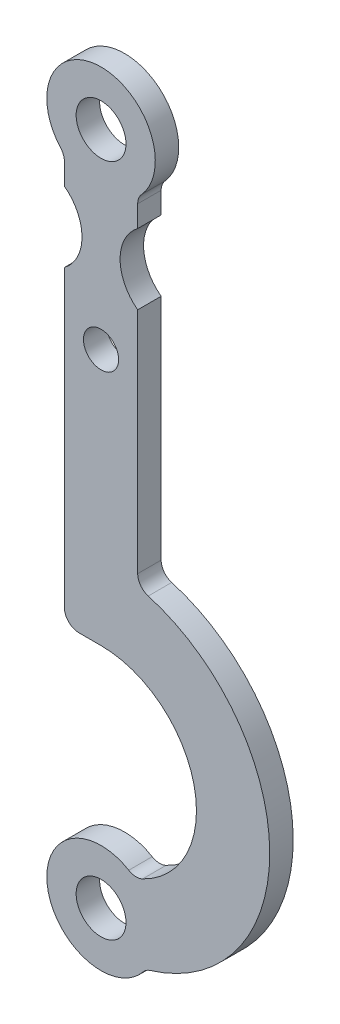
from build123d import *

# Parameters (mm, degrees)
SKETCH1_R           = 6
SKETCH1_R_2         = 8.5
BOSS_EXTRUDE1_DEPTH = 8
FILLET1_R           = 5


with BuildPart() as part:
    # Sketch1 → Boss-Extrude1 (new body)
    with BuildSketch(Plane.XY):
        with BuildLine():
            ThreePointArc((12.5, -13.638181697), (0, 18.5), (-12.5, -13.638181697))
            Line((-12.5, -13.638181697), (-12.5, -23))
            ThreePointArc((-12.5, -23), (-6.5, -35), (-12.5, -47))
            Line((-12.5, -47), (-12.5, -152.456671403))
            Line((-12.5, -152.456671403), (0, -152.456671403))
            ThreePointArc((0, -152.456671403), (32.019441409, -179.184193262), (11.444366088, -215.464647068))
            ThreePointArc((11.444366088, -215.464647068), (-18.29086587, -232.773846738), (15.239317045, -240.488718511))
            ThreePointArc((15.239317045, -240.488718511), (57.52601951, -183.58870793), (12.5, -128.830749818))
            Line((12.5, -128.830749818), (12.5, -47))
            ThreePointArc((12.5, -47), (6.5, -35), (12.5, -23))
            Line((12.5, -23), (12.5, -13.638181697))
        make_face()
        with BuildLine():
            ThreePointArc((8.333859781, -228.327642037), (8.458362966, -229.159704854), (8.5, -230))
            ThreePointArc((8.5, -230), (-8.458362966, -230.840295146), (8.333859781, -228.327642037))
        make_face(mode=Mode.SUBTRACT)
        with Locations((0, -65)):
            Circle(SKETCH1_R, mode=Mode.SUBTRACT)
        Circle(SKETCH1_R_2, mode=Mode.SUBTRACT)
    extrude(amount=BOSS_EXTRUDE1_DEPTH)

    # Fillet1
    fillet1_edges = [part.edges().sort_by_distance(p)[0] for p in [
        (11.444366088, -215.464647068, 4),
        (-12.5, -152.456671403, 4),
        (-12.5, -13.638181697, 4),
        (12.5, -13.638181697, 4),
        (12.5, -128.830749818, 4),
        (15.239317045, -240.488718511, 4),
    ]]
    fillet(fillet1_edges, radius=FILLET1_R)


solid = part.part
